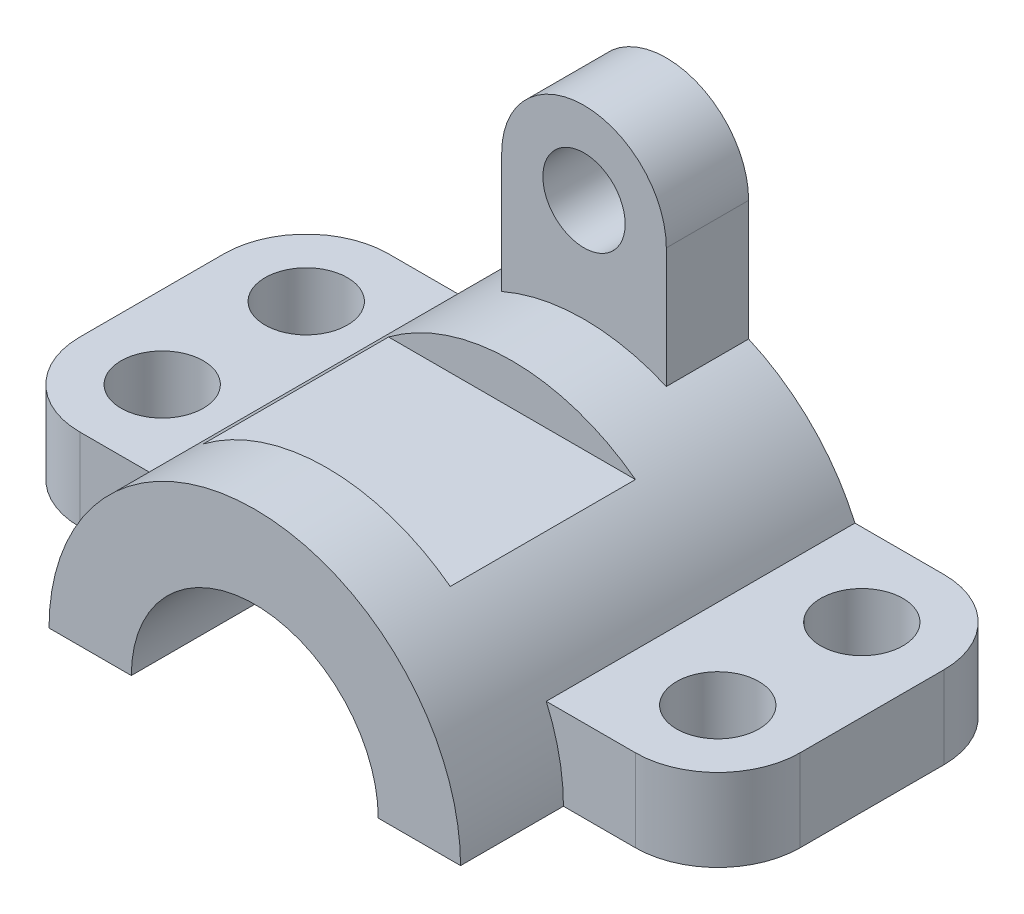
from build123d import *

# Parameters (mm, degrees)
EXTRUDE_1_DEPTH     = 80
SKETCH_3_R          = 8
EXTRUDE_2_DEPTH     = 16
SKETCH_4_W          = 84.547176069
SKETCH_4_H          = 36
CUT_EXTRUDE_1_DEPTH = 33
SKETCH_5_R          = 8
EXTRUDE_3_DEPTH     = 16


with BuildPart() as part:
    # 草图2 → 凸台-拉伸1 (new body)
    with BuildSketch(Plane.XY):
        with BuildLine():
            Line((-40, 0), (-24, 0))
            ThreePointArc((-24, 0), (0, 24), (24, 0))
            Line((24, 0), (40, 0))
            ThreePointArc((40, 0), (0, 40), (-40, 0))
        make_face()
    extrude(amount=EXTRUDE_1_DEPTH)

    # 草图3 → 凸台-拉伸2 (add)
    with BuildSketch(Plane(origin=(0, 0, 0), x_dir=(1, 0, 0), z_dir=(0, 1, 0))):
        with BuildLine():
            Line((32.951730358, 0), (54, 0))
            ThreePointArc((54, 0), (65.313708499, -4.686291501), (70, -16))
            Line((70, -16), (70, -44))
            ThreePointArc((70, -44), (65.313708499, -55.313708499), (54, -60))
            Line((54, -60), (32.951730358, -60))
            Line((32.951730358, -60), (32.951730358, 0))
        make_face()
        with Locations((54, -16)):
            Circle(SKETCH_3_R, mode=Mode.SUBTRACT)
        with Locations((54, -44)):
            Circle(SKETCH_3_R, mode=Mode.SUBTRACT)
        with BuildLine():
            Line((-32.951730358, -60), (-32.951730358, 0))
            Line((-32.951730358, 0), (-54, 0))
            ThreePointArc((-54, 0), (-65.313708499, -4.686291501), (-70, -16))
            Line((-70, -16), (-70, -44))
            ThreePointArc((-70, -44), (-65.313708499, -55.313708499), (-54, -60))
            Line((-54, -60), (-32.951730358, -60))
        make_face()
        with Locations((-54, -44)):
            Circle(SKETCH_3_R, mode=Mode.SUBTRACT)
        with Locations((-54, -16)):
            Circle(SKETCH_3_R, mode=Mode.SUBTRACT)
    extrude(amount=EXTRUDE_2_DEPTH)

    # 草图4 → 切除-拉伸1 (cut)
    with BuildSketch(Plane(origin=(0, 32, 0), x_dir=(1, 0, 0), z_dir=(0, 1, 0))):
        with Locations((0.989381847, -48)):
            Rectangle(SKETCH_4_W, SKETCH_4_H)
    extrude(amount=CUT_EXTRUDE_1_DEPTH, mode=Mode.SUBTRACT)

    # 草图5 → 凸台-拉伸3 (add)
    with BuildSketch(Plane.XY):
        with BuildLine():
            Line((-16, 60), (-16, 36.66060556))
            Line((-16, 36.66060556), (16, 36.66060556))
            Line((16, 36.66060556), (16, 60))
            ThreePointArc((16, 60), (0, 76), (-16, 60))
        make_face()
        with Locations((0, 60)):
            Circle(SKETCH_5_R, mode=Mode.SUBTRACT)
    extrude(amount=EXTRUDE_3_DEPTH)


solid = part.part
